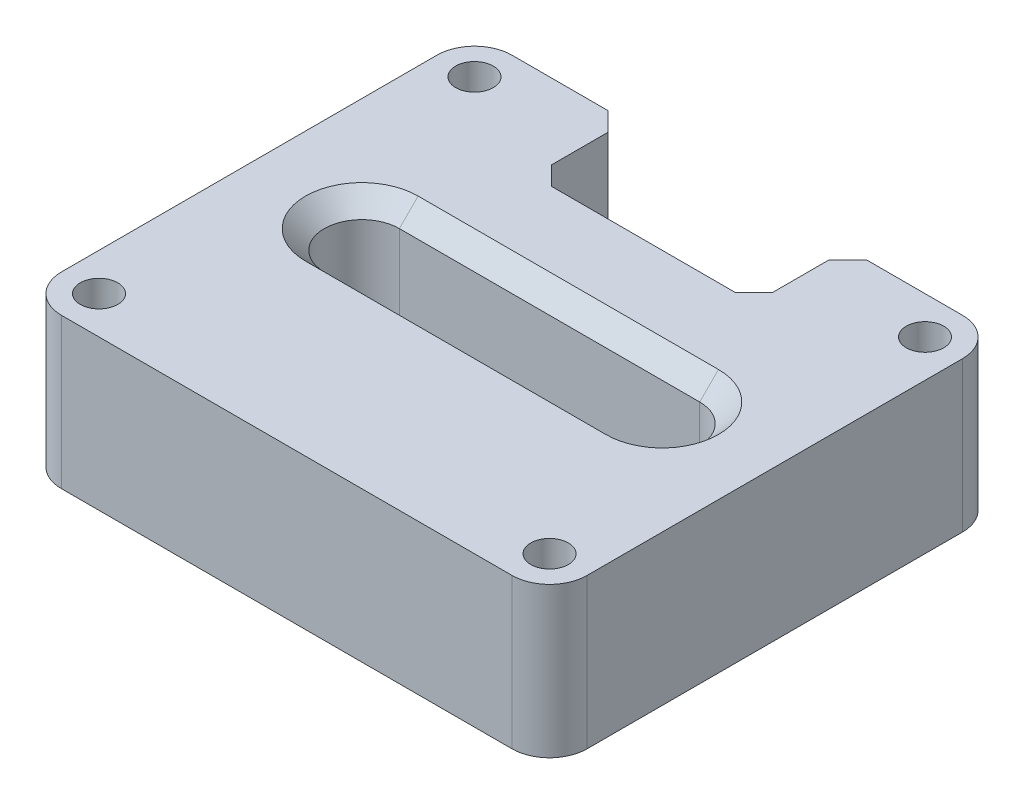
from build123d import *

# Parameters (mm, degrees)
SKETCH1_R           = 5
BOSS_EXTRUDE2_DEPTH = 40
CHAMFER1_SIZE       = 5


with BuildPart() as part:
    # Sketch1 → Boss-Extrude2 (new body)
    with BuildSketch(Plane(origin=(0, 0, 0), x_dir=(1, 0, 0), z_dir=(0, 1, 0))):
        with BuildLine():
            Line((-60, 60), (-34.43523791, 60))
            Line((-34.43523791, 60), (-29.43523791, 55))
            Line((-29.43523791, 55), (-29.43523791, 40))
            Line((-29.43523791, 40), (-24.43523791, 35))
            Line((-24.43523791, 35), (24.43523791, 35))
            Line((24.43523791, 35), (29.43523791, 40))
            Line((29.43523791, 40), (29.43523791, 55))
            Line((29.43523791, 55), (34.43523791, 60))
            Line((34.43523791, 60), (60, 60))
            ThreePointArc((60, 60), (67.071067812, 57.071067812), (70, 50))
            Line((70, 50), (70, -50))
            ThreePointArc((70, -50), (67.071067812, -57.071067812), (60, -60))
            Line((60, -60), (-60, -60))
            ThreePointArc((-60, -60), (-67.071067812, -57.071067812), (-70, -50))
            Line((-70, -50), (-70, 50))
            ThreePointArc((-70, 50), (-67.071067812, 57.071067812), (-60, 60))
        make_face()
        with Locations((-60, 50)):
            Circle(SKETCH1_R, mode=Mode.SUBTRACT)
        with Locations((60, 50)):
            Circle(SKETCH1_R, mode=Mode.SUBTRACT)
        with Locations((60, -50)):
            Circle(SKETCH1_R, mode=Mode.SUBTRACT)
        with Locations((-60, -50)):
            Circle(SKETCH1_R, mode=Mode.SUBTRACT)
        with BuildLine():
            Line((-40, 10), (40, 10))
            ThreePointArc((40, 10), (50, 0), (40, -10))
            Line((40, -10), (-40, -10))
            ThreePointArc((-40, -10), (-50, 0), (-40, 10))
        make_face(mode=Mode.SUBTRACT)
    extrude(amount=BOSS_EXTRUDE2_DEPTH)

    # Chamfer1
    chamfer1_edges = [part.edges().sort_by_distance(p)[0] for p in [
        (-50, 0, 0),
        (0, 0, 10),
        (50, 0, 0),
        (0, 0, -10),
        (-50, 40, 0),
        (0, 40, 10),
        (50, 40, 0),
        (0, 40, -10),
    ]]
    chamfer(chamfer1_edges, length=CHAMFER1_SIZE)


solid = part.part
